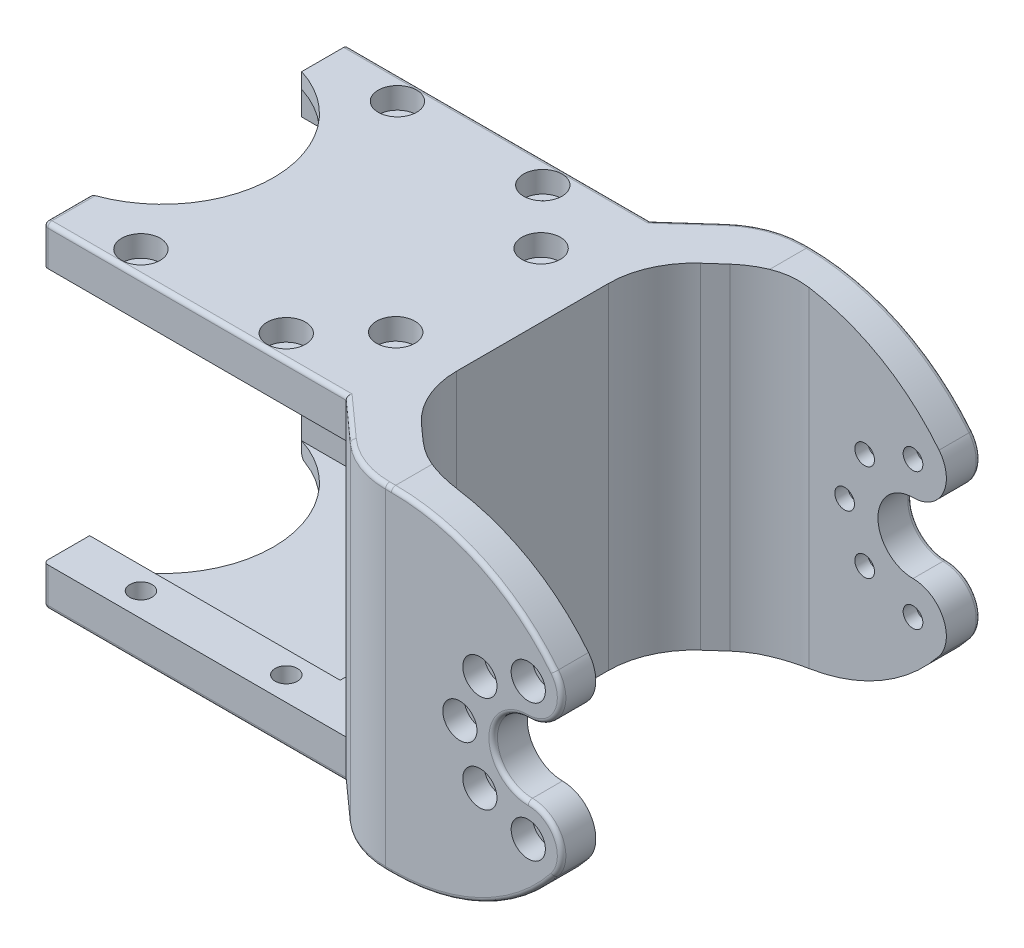
from build123d import *

# Parameters (mm, degrees)
SKETCH1_R           = 1.3
BOSS_EXTRUDE1_DEPTH = 2.8
SKETCH2_R           = 1.3
BOSS_EXTRUDE2_DEPTH = 1.8
SKETCH3_R           = 2.25
CUT_EXTRUDE1_DEPTH  = 2.5
SKETCH4_W           = 35.6
SKETCH4_H           = 4.6
BOSS_EXTRUDE3_DEPTH = 5
SKETCH5_W           = 4
SKETCH5_H           = 35.6
BOSS_EXTRUDE4_DEPTH = 15
SKETCH8_R           = 1.15
BOSS_EXTRUDE5_DEPTH = 4
BOSS_EXTRUDE7_DEPTH = 39.2
FILLET1_R           = 10
FILLET2_R           = 0.5
SKETCH12_R          = 2
CUT_EXTRUDE2_DEPTH  = 2.5


with BuildPart() as part:
    # Sketch1 → Boss-Extrude1 (new body)
    with BuildSketch(Plane(origin=(0, 0, 0), x_dir=(1, 0, 0), z_dir=(0, 1, 0))):
        Polygon((33.2, 12.4), (33.2, -12.4), (3.903844259, -12.4), (3.903844259, -17.8), (38.3, -17.8), (38.3, 17.8), (3.903844259, 17.8), (3.903844259, 12.4), align=None)
        with Locations((12.5, 15)):
            Circle(SKETCH1_R, mode=Mode.SUBTRACT)
        with Locations((29.5, 15)):
            Circle(SKETCH1_R, mode=Mode.SUBTRACT)
        with Locations((29.5, -15)):
            Circle(SKETCH1_R, mode=Mode.SUBTRACT)
        with Locations((12.5, -15)):
            Circle(SKETCH1_R, mode=Mode.SUBTRACT)
        with Locations((35.8, -8.5)):
            Circle(SKETCH1_R, mode=Mode.SUBTRACT)
        with Locations((35.8, 8.5)):
            Circle(SKETCH1_R, mode=Mode.SUBTRACT)
    extrude(amount=BOSS_EXTRUDE1_DEPTH)

    # Sketch2 → Boss-Extrude2 (add)
    with BuildSketch(Plane(origin=(0, 2.8, 0), x_dir=(1, 0, 0), z_dir=(0, 1, 0))):
        with BuildLine():
            Line((3.903844259, -12.4), (3.903844259, -17.8))
            Line((3.903844259, -17.8), (38.3, -17.8))
            Line((38.3, -17.8), (38.3, 17.8))
            Line((38.3, 17.8), (3.903844259, 17.8))
            Line((3.903844259, 17.8), (3.903844259, 12.4))
            ThreePointArc((3.903844259, 12.4), (13, 0), (3.903844259, -12.4))
        make_face()
        with Locations((12.5, -15)):
            Circle(SKETCH2_R, mode=Mode.SUBTRACT)
        with Locations((29.5, -15)):
            Circle(SKETCH2_R, mode=Mode.SUBTRACT)
        with Locations((35.8, -8.5)):
            Circle(SKETCH2_R, mode=Mode.SUBTRACT)
        with Locations((35.8, 8.5)):
            Circle(SKETCH2_R, mode=Mode.SUBTRACT)
        with Locations((29.5, 15)):
            Circle(SKETCH2_R, mode=Mode.SUBTRACT)
        with Locations((12.5, 15)):
            Circle(SKETCH2_R, mode=Mode.SUBTRACT)
    extrude(amount=BOSS_EXTRUDE2_DEPTH)

    # Sketch3 → Cut-Extrude1 (cut)
    with BuildSketch(Plane(origin=(0, 4.6, 0), x_dir=(1, 0, 0), z_dir=(0, 1, 0))):
        with Locations((12.5, 15)):
            Circle(SKETCH3_R)
        with Locations((29.5, 15)):
            Circle(SKETCH3_R)
        with Locations((35.8, 8.5)):
            Circle(SKETCH3_R)
        with Locations((35.8, -8.5)):
            Circle(SKETCH3_R)
        with Locations((29.5, -15)):
            Circle(SKETCH3_R)
        with Locations((12.5, -15)):
            Circle(SKETCH3_R)
    extrude(amount=-CUT_EXTRUDE1_DEPTH, mode=Mode.SUBTRACT)

    # Sketch4 → Boss-Extrude3 (add)
    with BuildSketch(Plane(origin=(38.3, 0, 0), x_dir=(0, 0, -1), z_dir=(1, 0, 0))):
        with Locations((0, 2.3)):
            Rectangle(SKETCH4_W, SKETCH4_H)
    extrude(amount=BOSS_EXTRUDE3_DEPTH)

    # Sketch5 → Boss-Extrude4 (add)
    with BuildSketch(Plane.XZ):
        with Locations((41.3, 0)):
            Rectangle(SKETCH5_W, SKETCH5_H)
    extrude(amount=BOSS_EXTRUDE4_DEPTH)

    # Mirror1: part across plane


with BuildPart() as part_1:
    add(part.part)
    add(part.part.mirror(Plane.ZX.offset(-15)))



with BuildPart() as body_2:
    # Sketch8 → Boss-Extrude5 (new body)
    with BuildSketch(Plane.XY.offset(20.5)):
        with BuildLine():
            Line((51.3, -34.6), (51.3, 4.6))
            ThreePointArc((51.3, 4.6), (61.869424146, 2.18906316), (70.3478607, -4.566782962))
            ThreePointArc((70.3478607, -4.566782962), (70.814224413, -8.691220499), (67.3, -10.9))
            ThreePointArc((67.3, -10.9), (63.2, -15), (67.3, -19.1))
            ThreePointArc((67.3, -19.1), (70.814224413, -21.308779501), (70.3478607, -25.433217038))
            ThreePointArc((70.3478607, -25.433217038), (61.869424146, -32.18906316), (51.3, -34.6))
        make_face()
        with Locations((67.3, -7)):
            Circle(SKETCH8_R, mode=Mode.SUBTRACT)
        with Locations((61.643145751, -9.343145751)):
            Circle(SKETCH8_R, mode=Mode.SUBTRACT)
        with Locations((59.3, -15)):
            Circle(SKETCH8_R, mode=Mode.SUBTRACT)
        with Locations((61.643145751, -20.656854249)):
            Circle(SKETCH8_R, mode=Mode.SUBTRACT)
        with Locations((67.3, -23)):
            Circle(SKETCH8_R, mode=Mode.SUBTRACT)
    extrude(amount=BOSS_EXTRUDE5_DEPTH)


with BuildPart() as part_2:
    add(part_1.part)

    add(body_2.part)  # Boss-Extrude7 merges body 2
    # Sketch11 → Boss-Extrude7 (add)
    with BuildSketch(Plane(origin=(0, 4.6, 0), x_dir=(1, 0, 0), z_dir=(0, 1, 0))):
        Polygon((43.3, -13.334288522), (39.3, -17.8), (46.780066726, -24.5), (51.3, -24.5), (51.3, -20.5), align=None)
    extrude(amount=-BOSS_EXTRUDE7_DEPTH)

    # Fillet1
    fillet1_edges = [part_2.edges().sort_by_distance(p)[0] for p in [
        (46.780066726, -15, 24.5),
        (51.3, -15, 20.5),
        (43.3, -15, 13.334288522),
    ]]
    fillet(fillet1_edges, radius=FILLET1_R)

    # Mirror6: part across plane


with BuildPart() as part_3:
    add(part_2.part)
    add(part_2.part.mirror(Plane.XY))

    # Fillet2
    fillet2_edges = [part_3.edges().sort_by_distance(p)[0] for p in [
        (41.615915378, -34.6, -19.874397676),
        (41.615915378, 4.6, -19.874397676),
        (47.032263012, -34.6, -23.840448424),
        (47.032263012, 4.6, -23.840448424),
        (50.951910275, -34.6, -24.5),
        (61.869424146, -32.18906316, -24.5),
        (70.814224413, -21.308779501, -24.5),
        (63.2, -15, -24.5),
        (70.814224413, -8.691220499, -24.5),
        (61.869424146, 2.18906316, -24.5),
        (50.951910275, 4.6, -24.5),
        (41.615915378, -34.6, 19.874397676),
        (41.615915378, 4.6, 19.874397676),
        (47.032263012, -34.6, 23.840448424),
        (50.951910275, -34.6, 24.5),
        (61.869424146, -32.18906316, 24.5),
        (70.814224413, -21.308779501, 24.5),
        (63.2, -15, 24.5),
        (70.814224413, -8.691220499, 24.5),
        (61.869424146, 2.18906316, 24.5),
        (50.951910275, 4.6, 24.5),
        (47.032263012, 4.6, 23.840448424),
        (3.903844259, -34.6, -15.1),
        (3.903844259, -32.3, -17.8),
        (21.60192213, -34.6, -17.8),
        (21.60192213, 4.6, -17.8),
        (3.903844259, -34.6, 15.1),
        (3.903844259, -32.3, 17.8),
        (21.60192213, -34.6, 17.8),
        (3.903844259, 2.3, 17.8),
        (3.903844259, 4.6, 15.1),
        (21.60192213, 4.6, 17.8),
    ]]
    fillet(fillet2_edges, radius=FILLET2_R)

    # Sketch12 → Cut-Extrude2 (cut)
    with BuildSketch(Plane.XY.offset(24.5)):
        with Locations((67.3, -23)):
            Circle(SKETCH12_R)
        with Locations((61.643145751, -20.656854249)):
            Circle(SKETCH12_R)
        with Locations((59.3, -15)):
            Circle(SKETCH12_R)
        with Locations((61.643145751, -9.343145751)):
            Circle(SKETCH12_R)
        with Locations((67.3, -7)):
            Circle(SKETCH12_R)
    cut_extrude2 = extrude(amount=-CUT_EXTRUDE2_DEPTH, mode=Mode.SUBTRACT)

    # Mirror7: Cut-Extrude2 across plane
    add(cut_extrude2.mirror(Plane.XY), mode=Mode.SUBTRACT)


solid = part_3.part
